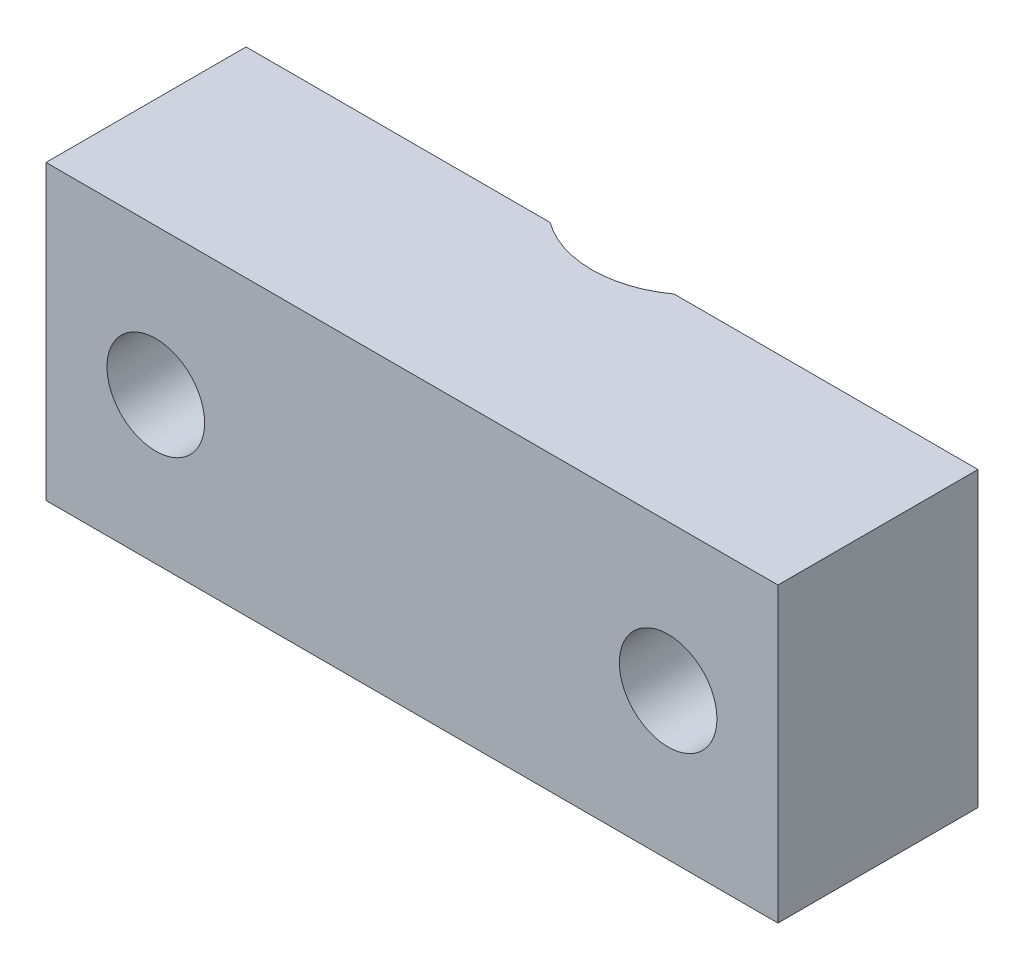
from build123d import *

# Parameters (mm, degrees)
SKETCH1_W           = 30
SKETCH1_H           = 12
SKETCH1_R           = 2
BOSS_EXTRUDE1_DEPTH = 8.2
SKETCH2_R           = 6.5
CUT_EXTRUDE1_DEPTH  = 7.2
SKETCH3_R           = 5.35
CUT_EXTRUDE2_DEPTH  = 9.9
SKETCH4_R           = 4.325
CUT_EXTRUDE3_DEPTH  = 13.9
CUT_EXTRUDE4_START  = -5.7
CUT_EXTRUDE4_DEPTH  = 1.4


with BuildPart() as part:
    # Sketch1 → Boss-Extrude1 (new body)
    with BuildSketch(Plane.XY):
        with Locations((-11.682314935, 31.556218858)):
            Rectangle(SKETCH1_W, SKETCH1_H)
        with Locations((-22.182314935, 31.556218858)):
            Circle(SKETCH1_R, mode=Mode.SUBTRACT)
        with Locations((-1.182314935, 31.556218858)):
            Circle(SKETCH1_R, mode=Mode.SUBTRACT)
    extrude(amount=BOSS_EXTRUDE1_DEPTH)

    # Sketch2 → Cut-Extrude1 (cut)
    with BuildSketch(Plane(origin=(0, 25.556218858, 0), x_dir=(-1, 0, 0), z_dir=(0, -1, 0))):
        with Locations((11.682314935, 3.5)):
            Circle(SKETCH2_R)
    extrude(amount=-CUT_EXTRUDE1_DEPTH, mode=Mode.SUBTRACT)

    # Sketch3 → Cut-Extrude2 (cut)
    with BuildSketch(Plane(origin=(0, 25.556218858, 0), x_dir=(-1, 0, 0), z_dir=(0, -1, 0))):
        with Locations((11.682314935, 3.5)):
            Circle(SKETCH3_R)
    extrude(amount=-CUT_EXTRUDE2_DEPTH, mode=Mode.SUBTRACT)

    # Sketch4 → Cut-Extrude3 (cut)
    with BuildSketch(Plane(origin=(0, 25.556218858, 0), x_dir=(-1, 0, 0), z_dir=(0, -1, 0))):
        with Locations((11.682314935, 3.5)):
            Circle(SKETCH4_R)
    extrude(amount=-CUT_EXTRUDE3_DEPTH, mode=Mode.SUBTRACT)

    # Sketch5 → Cut-Extrude4 (cut)
    with BuildSketch(Plane(origin=(0, 25.556218858, 0), x_dir=(-1, 0, 0), z_dir=(0, -1, 0)).offset(CUT_EXTRUDE4_START)):
        with BuildLine():
            Line((9.270124371, -4.128630198), (5.336263245, 1.191543622))
            Line((5.336263245, 1.191543622), (18.008683121, 1.191543622))
            Line((18.008683121, 1.191543622), (14.098774847, -4.122841808))
            ThreePointArc((14.098774847, -4.122841808), (11.685911211, -5.344997844), (9.270124371, -4.128630198))
        make_face()
    extrude(amount=CUT_EXTRUDE4_DEPTH, mode=Mode.SUBTRACT)


solid = part.part
